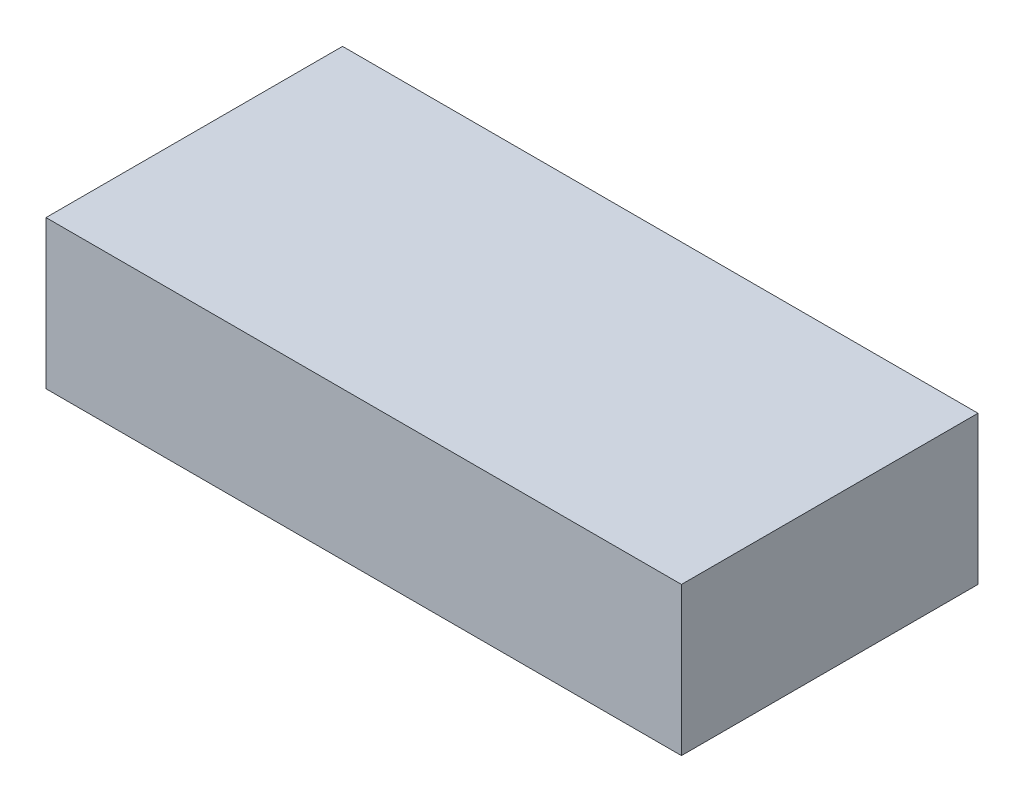
from build123d import *

# Parameters (mm, degrees)
SKETCH1_W           = 30
SKETCH1_H           = 14
BOSS_EXTRUDE1_DEPTH = 7


with BuildPart() as part:
    # Sketch1 → Boss-Extrude1 (new body)
    with BuildSketch(Plane(origin=(0, 0, 0), x_dir=(1, 0, 0), z_dir=(0, 1, 0))):
        Rectangle(SKETCH1_W, SKETCH1_H)
    extrude(amount=BOSS_EXTRUDE1_DEPTH)


solid = part.part
